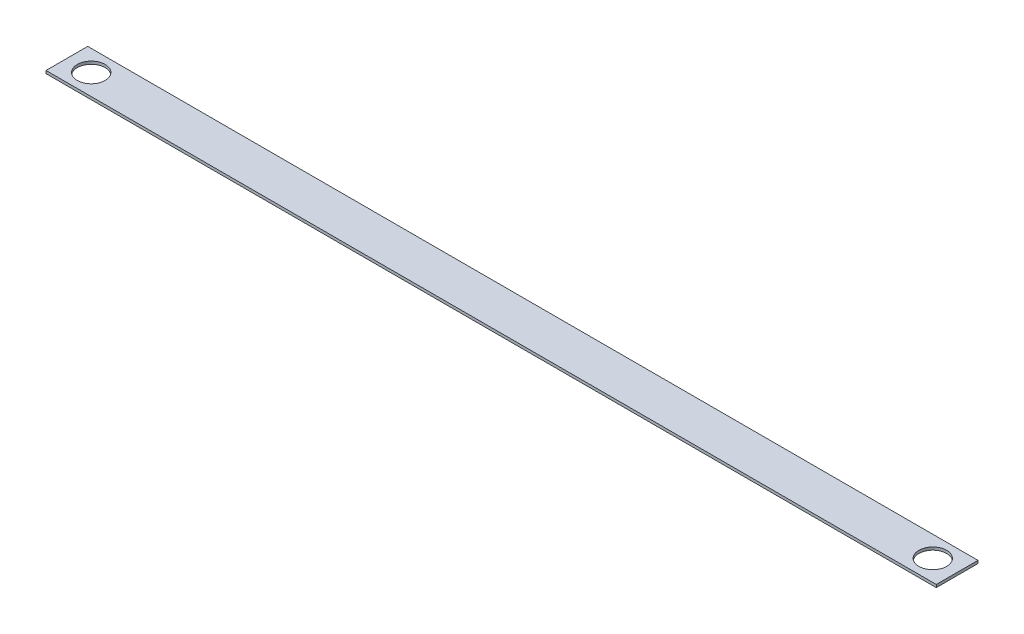
from build123d import *

# Parameters (mm, degrees)
SKETCH1_W               = 812.8
SKETCH1_H               = 38.1
BOSS_EXTRUDE1_DEPTH     = 2.54
SKETCH2_R               = 12.7
CUT_EXTRUDE1_DEPTH      = 1
CUT_EXTRUDE1_DEPTH_BACK = 3.54


with BuildPart() as part:
    # Sketch1 → Boss-Extrude1 (new body)
    with BuildSketch(Plane(origin=(0, 0, 0), x_dir=(1, 0, 0), z_dir=(0, 1, 0))):
        Rectangle(SKETCH1_W, SKETCH1_H)
    extrude(amount=BOSS_EXTRUDE1_DEPTH)

    # Sketch2 → Cut-Extrude1 (cut, two sides)
    with BuildSketch(Plane(origin=(0, 2.54, 0), x_dir=(1, 0, 0), z_dir=(0, 1, 0))) as cut_extrude1_sk:
        with Locations((-384.175, 0)):
            Circle(SKETCH2_R)
        with Locations((384.175, 0)):
            Circle(SKETCH2_R)
    extrude(amount=CUT_EXTRUDE1_DEPTH, mode=Mode.SUBTRACT)
    extrude(cut_extrude1_sk.sketch, amount=-CUT_EXTRUDE1_DEPTH_BACK, mode=Mode.SUBTRACT)


solid = part.part
